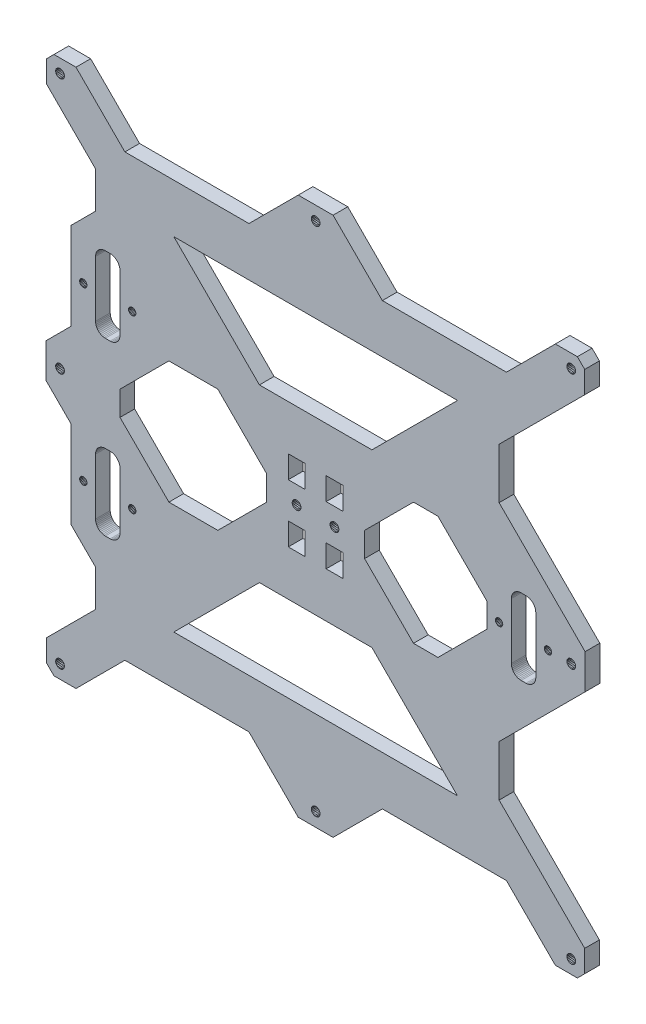
from build123d import *

# Parameters (mm, degrees)
SKETCH1_W           = 6.800001917
SKETCH1_H           = 9.1999977
SKETCH1_H_2         = 9.199995837
BOSS_EXTRUDE1_DEPTH = 6


with BuildPart() as part:
    # Sketch1 → Boss-Extrude1 (new body)
    with BuildSketch(Plane.XY):
        Polygon((253.104853661, 139.09486987), (273.104846061, 159.09486227), (323.830955709, 159.09486227), (343.983501837, 138.942316142), (358.226140366, 138.942316142), (378.378686494, 159.09486227), (429.104796141, 159.09486227), (449.104788541, 139.09486987), (458.104786861, 139.09486987), (461.104785901, 142.09486891), (461.104785901, 151.09486723), (426.104798301, 186.09485483), (426.104798301, 206.820974078), (461.272022357, 241.988198133), (461.272022357, 256.230836662), (426.104798301, 291.398060718), (426.104798301, 312.09481451), (461.104785901, 347.09480211), (461.104785901, 356.09480043), (458.104786861, 359.09479947), (449.104788541, 359.09479947), (429.104796141, 339.09480707), (378.378686494, 339.09480707), (358.226140366, 359.247353198), (343.983501837, 359.247353198), (323.830955709, 339.09480707), (273.104846061, 339.09480707), (253.104853661, 359.09479947), (244.104855341, 359.09479947), (241.104856301, 356.09480043), (241.104856301, 347.09480211), (261.104849901, 327.09480851), (261.104849901, 312.09481451), (251.104853101, 302.09481771), (251.104853101, 266.368704463), (240.937619846, 256.201471208), (240.937619846, 241.958832678), (251.104853101, 231.791599423), (251.104853101, 196.09485163), (261.104849901, 186.09485483), (261.104849901, 171.09486083), (241.104856301, 151.09486723), (241.104856301, 142.09486891), (244.104855341, 139.09486987), align=None)
        Polygon((263.574115382, 229.790358978), (263.104849261, 229.558942537), (262.669803685, 229.268254376), (262.276422402, 228.92326825), (261.931436276, 228.529886967), (261.640748115, 228.09484139), (261.409331674, 227.62557527), (261.241146553, 227.130117879), (261.139070445, 226.616946632), (261.104849901, 226.09484203), (261.104849901, 203.09484939), (261.139070445, 202.572744789), (261.241146553, 202.059573541), (261.409331674, 201.564116151), (261.640748115, 201.09485003), (261.931436276, 200.659804454), (262.276422402, 200.266423171), (262.669803685, 199.921437045), (263.104849261, 199.630748884), (263.574115382, 199.399332443), (264.069572772, 199.231147322), (264.58274402, 199.129071214), (265.104848621, 199.09485067), (267.104847981, 199.09485067), (267.626952583, 199.129071214), (268.140123831, 199.231147322), (268.635581221, 199.399332443), (269.104847341, 199.630748884), (269.539892918, 199.921437045), (269.933274201, 200.266423171), (270.278260327, 200.659804454), (270.568948488, 201.09485003), (270.800364929, 201.564116151), (270.96855005, 202.059573541), (271.070626158, 202.572744789), (271.104846701, 203.09484939), (271.104846701, 226.09484203), (271.070626158, 226.616946632), (270.96855005, 227.130117879), (270.800364929, 227.62557527), (270.568948488, 228.09484139), (270.278260327, 228.529886967), (269.933274201, 228.92326825), (269.539892918, 229.268254376), (269.104847341, 229.558942537), (268.635581221, 229.790358978), (268.140123831, 229.958544099), (267.626952583, 230.060620207), (267.104847981, 230.09484075), (265.104848621, 230.09484075), (264.58274402, 230.060620207), (264.069572772, 229.958544099), align=None, mode=Mode.SUBTRACT)
        Polygon((274.805807411, 284.84482323), (274.655956826, 284.483051914), (274.604845581, 284.09482347), (274.655956826, 283.706595027), (274.805807411, 283.34482371), (275.044185269, 283.034163638), (275.354845341, 282.79578578), (275.716616658, 282.645935195), (276.104845101, 282.59482395), (276.493073545, 282.645935195), (276.854844861, 282.79578578), (277.165504934, 283.034163638), (277.403882791, 283.34482371), (277.553733377, 283.706595027), (277.604844621, 284.09482347), (277.553733377, 284.483051914), (277.403882791, 284.84482323), (277.165504934, 285.155483303), (276.854844861, 285.39386116), (276.493073545, 285.543711746), (276.104845101, 285.59482299), (275.716616658, 285.543711746), (275.354845341, 285.39386116), (275.044185269, 285.155483303), align=None, mode=Mode.SUBTRACT)
        Polygon((445.044130869, 248.034174838), (445.354790941, 247.79579698), (445.716562258, 247.645946395), (446.104790701, 247.59483515), (446.493019145, 247.645946395), (446.854790461, 247.79579698), (447.165450534, 248.034174838), (447.403828391, 248.34483491), (447.553678977, 248.706606227), (447.604790221, 249.09483467), (447.553678977, 249.483063114), (447.403828391, 249.84483443), (447.165450534, 250.155494503), (446.854790461, 250.39387236), (446.493019145, 250.543722946), (446.104790701, 250.59483419), (445.716562258, 250.543722946), (445.354790941, 250.39387236), (445.044130869, 250.155494503), (444.805753011, 249.84483443), (444.655902426, 249.483063114), (444.604791181, 249.09483467), (444.655902426, 248.706606227), (444.805753011, 248.34483491), align=None, mode=Mode.SUBTRACT)
        Polygon((427.403834791, 249.84483443), (427.165456934, 250.155494503), (426.854796861, 250.39387236), (426.493025545, 250.543722946), (426.104797101, 250.59483419), (425.716568658, 250.543722946), (425.354797341, 250.39387236), (425.044137269, 250.155494503), (424.805759411, 249.84483443), (424.655908826, 249.483063114), (424.604797581, 249.09483467), (424.655908826, 248.706606227), (424.805759411, 248.34483491), (425.044137269, 248.034174838), (425.354797341, 247.79579698), (425.716568658, 247.645946395), (426.104797101, 247.59483515), (426.493025545, 247.645946395), (426.854796861, 247.79579698), (427.165456934, 248.034174838), (427.403834791, 248.34483491), (427.553685377, 248.706606227), (427.604796621, 249.09483467), (427.553685377, 249.483063114), align=None, mode=Mode.SUBTRACT)
        Polygon((433.574060982, 263.653224535), (433.104794861, 263.421808094), (432.669749285, 263.131119933), (432.276368002, 262.786133807), (431.931381876, 262.392752524), (431.640693715, 261.957706947), (431.409277274, 261.488440827), (431.241092153, 260.992983436), (431.139016045, 260.479812189), (431.104795501, 259.957707587), (431.104795501, 236.957714947), (431.139016045, 236.435610345), (431.241092153, 235.922439098), (431.409277274, 235.426981708), (431.640693715, 234.957715587), (431.931381876, 234.52267001), (432.276368002, 234.129288728), (432.669749285, 233.784302601), (433.104794861, 233.493614441), (433.574060982, 233.262198), (434.069518372, 233.094012878), (434.58268962, 232.991936771), (435.104794221, 232.957716227), (437.104793581, 232.957716227), (437.626898183, 232.991936771), (438.140069431, 233.094012878), (438.635526821, 233.262198), (439.104792941, 233.493614441), (439.539838518, 233.784302601), (439.933219801, 234.129288728), (440.278205927, 234.52267001), (440.568894088, 234.957715587), (440.800310529, 235.426981708), (440.96849565, 235.922439098), (441.070571758, 236.435610345), (441.104792301, 236.957714947), (441.104792301, 259.957707587), (441.070571758, 260.479812189), (440.96849565, 260.992983436), (440.800310529, 261.488440827), (440.568894088, 261.957706947), (440.278205927, 262.392752524), (439.933219801, 262.786133807), (439.539838518, 263.131119933), (439.104792941, 263.421808094), (438.635526821, 263.653224535), (438.140069431, 263.821409656), (437.626898183, 263.923485764), (437.104793581, 263.957706307), (435.104794221, 263.957706307), (434.58268962, 263.923485764), (434.069518372, 263.821409656), align=None, mode=Mode.SUBTRACT)
        Polygon((270.96855005, 297.137132373), (270.800364929, 297.632589764), (270.568948488, 298.101855884), (270.278260327, 298.536901461), (269.933274201, 298.930282744), (269.539892918, 299.27526887), (269.104847341, 299.565957031), (268.635581221, 299.797373472), (268.140123831, 299.965558593), (267.626952583, 300.067634701), (267.104847981, 300.101855244), (265.104848621, 300.101855244), (264.58274402, 300.067634701), (264.069572772, 299.965558593), (263.574115382, 299.797373472), (263.104849261, 299.565957031), (262.669803685, 299.27526887), (262.276422402, 298.930282744), (261.931436276, 298.536901461), (261.640748115, 298.101855884), (261.409331674, 297.632589764), (261.241146553, 297.137132373), (261.139070445, 296.623961126), (261.104849901, 296.101856524), (261.104849901, 273.101863884), (261.139070445, 272.579759282), (261.241146553, 272.066588035), (261.409331674, 271.571130645), (261.640748115, 271.101864524), (261.931436276, 270.666818947), (262.276422402, 270.273437665), (262.669803685, 269.928451538), (263.104849261, 269.637763378), (263.574115382, 269.406346937), (264.069572772, 269.238161815), (264.58274402, 269.136085708), (265.104848621, 269.101865164), (267.104847981, 269.101865164), (267.626952583, 269.136085708), (268.140123831, 269.238161815), (268.635581221, 269.406346937), (269.104847341, 269.637763378), (269.539892918, 269.928451538), (269.933274201, 270.273437665), (270.278260327, 270.666818947), (270.568948488, 271.101864524), (270.800364929, 271.571130645), (270.96855005, 272.066588035), (271.070626158, 272.579759282), (271.104846701, 273.101863884), (271.104846701, 296.101856524), (271.070626158, 296.623961126), align=None, mode=Mode.SUBTRACT)
        Polygon((276.854844861, 212.79580818), (277.165504934, 213.034186038), (277.403882791, 213.34484611), (277.553733377, 213.706617427), (277.604844621, 214.09484587), (277.553733377, 214.483074314), (277.403882791, 214.84484563), (277.165504934, 215.155505703), (276.854844861, 215.39388356), (276.493073545, 215.543734146), (276.104845101, 215.59484539), (275.716616658, 215.543734146), (275.354845341, 215.39388356), (275.044185269, 215.155505703), (274.805807411, 214.84484563), (274.655956826, 214.483074314), (274.604845581, 214.09484587), (274.655956826, 213.706617427), (274.805807411, 213.34484611), (275.044185269, 213.034186038), (275.354845341, 212.79580818), (275.716616658, 212.645957595), (276.104845101, 212.59484635), (276.493073545, 212.645957595), align=None, mode=Mode.SUBTRACT)
        Polygon((352.663666329, 352.705183774), (352.843487032, 353.139309354), (352.904820525, 353.605183486), (352.843487032, 354.071057619), (352.663666329, 354.505183198), (352.3776129, 354.877975285), (352.038451747, 355.131743055), (352.004820813, 355.164028714), (351.570695234, 355.343849417), (351.104821101, 355.40518291), (350.638946969, 355.343849417), (350.204821389, 355.164028714), (349.832029303, 354.877975285), (349.545975873, 354.505183198), (349.36615517, 354.071057619), (349.304821677, 353.605183486), (349.36615517, 353.139309354), (349.545975873, 352.705183774), (349.832029303, 352.332391688), (350.204821389, 352.046338258), (350.638946969, 351.866517555), (351.104821101, 351.805184062), (351.570695234, 351.866517555), (352.004820813, 352.046338258), (352.3776129, 352.332391688), align=None, mode=Mode.SUBTRACT)
        Polygon((256.104851501, 285.59482299), (255.716623058, 285.543711746), (255.354851741, 285.39386116), (255.044191669, 285.155483303), (254.805813811, 284.84482323), (254.655963226, 284.483051914), (254.604851981, 284.09482347), (254.655963226, 283.706595027), (254.805813811, 283.34482371), (255.044191669, 283.034163638), (255.354851741, 282.79578578), (255.716623058, 282.645935195), (256.104851501, 282.59482395), (256.493079945, 282.645935195), (256.854851261, 282.79578578), (257.165511334, 283.034163638), (257.403889191, 283.34482371), (257.553739777, 283.706595027), (257.604851021, 284.09482347), (257.553739777, 284.483051914), (257.403889191, 284.84482323), (257.165511334, 285.155483303), (256.854851261, 285.39386116), (256.493079945, 285.543711746), align=None, mode=Mode.SUBTRACT)
        Polygon((350.204821389, 146.143331082), (349.832029303, 145.857277653), (349.545975873, 145.484485566), (349.36615517, 145.050359986), (349.304821677, 144.584485854), (349.36615517, 144.118611722), (349.545975873, 143.684486142), (349.832029303, 143.311694055), (350.171190455, 143.057926285), (350.204821389, 143.025640626), (350.638946969, 142.845819923), (351.104821101, 142.78448643), (351.570695234, 142.845819923), (352.004820813, 143.025640626), (352.3776129, 143.311694055), (352.663666329, 143.684486142), (352.843487032, 144.118611722), (352.904820525, 144.584485854), (352.843487032, 145.050359986), (352.663666329, 145.484485566), (352.3776129, 145.857277653), (352.004820813, 146.143331082), (351.570695234, 146.323151785), (351.104821101, 146.384485278), (350.638946969, 146.323151785), align=None, mode=Mode.SUBTRACT)
        Polygon((293.104842061, 319.09481107), (409.104800141, 319.09481107), (374.104812541, 284.09482347), (328.104829661, 284.09482347), align=None, mode=Mode.SUBTRACT)
        Polygon((456.515169629, 146.143331082), (456.08104405, 146.323151785), (455.615169917, 146.384485278), (455.149295785, 146.323151785), (454.715170205, 146.143331082), (454.342378119, 145.857277653), (454.05632469, 145.484485566), (453.876503987, 145.050359986), (453.815170493, 144.584485854), (453.876503987, 144.118611722), (454.05632469, 143.684486142), (454.342378119, 143.311694055), (454.715170205, 143.025640626), (455.149295785, 142.845819923), (455.615169917, 142.78448643), (456.08104405, 142.845819923), (456.515169629, 143.025640626), (456.887961716, 143.311694055), (457.174015145, 143.684486142), (457.353835848, 144.118611722), (457.415169341, 144.584485854), (457.353835848, 145.050359986), (457.174015145, 145.484485566), (456.887961716, 145.857277653), align=None, mode=Mode.SUBTRACT)
        Polygon((245.677096869, 143.056566967), (246.109184437, 142.871902845), (246.57434357, 142.805363492), (247.040874441, 142.861483455), (247.476983743, 143.036438251), (247.852951348, 143.318305001), (248.143155685, 143.68787495), (248.327819807, 144.119962518), (248.39435916, 144.585121651), (248.338239197, 145.051652522), (248.163284401, 145.487761824), (247.881417651, 145.863729429), (247.511847702, 146.153933766), (247.079760134, 146.338597888), (246.614601001, 146.405137241), (246.14807013, 146.349017278), (245.711960827, 146.174062482), (245.335993222, 145.892195732), (245.045788886, 145.522625783), (244.861124764, 145.090538215), (244.794585411, 144.625379082), (244.850705374, 144.158848211), (245.02566017, 143.722738908), (245.30752692, 143.346771303), align=None, mode=Mode.SUBTRACT)
        Polygon((454.356690855, 250.381780036), (454.066486518, 250.012210087), (453.881822396, 249.580122519), (453.815283043, 249.114963386), (453.871403006, 248.648432515), (454.046357802, 248.212323212), (454.328224552, 247.836355607), (454.697794501, 247.546151271), (455.129882069, 247.361487149), (455.595041202, 247.294947796), (456.061572073, 247.351067759), (456.497681376, 247.526022555), (456.87364898, 247.807889305), (457.163853317, 248.177459254), (457.348517439, 248.609546822), (457.415056792, 249.074705955), (457.358936829, 249.541236826), (457.183982033, 249.977346128), (456.902115283, 250.353313733), (456.532545334, 250.64351807), (456.100457766, 250.828182192), (455.635298633, 250.894721545), (455.168767762, 250.838601582), (454.732658459, 250.663646786), align=None, mode=Mode.SUBTRACT)
        Polygon((244.794585411, 249.114963386), (244.850705374, 248.648432515), (245.02566017, 248.212323212), (245.30752692, 247.836355607), (245.677096869, 247.546151271), (246.109184437, 247.361487149), (246.57434357, 247.294947796), (247.040874441, 247.351067759), (247.476983743, 247.526022555), (247.852951348, 247.807889305), (248.143155685, 248.177459254), (248.327819807, 248.609546822), (248.39435916, 249.074705955), (248.338239197, 249.541236826), (248.163284401, 249.977346128), (247.881417651, 250.353313733), (247.511847702, 250.64351807), (247.079760134, 250.828182192), (246.614601001, 250.894721545), (246.14807013, 250.838601582), (245.711960827, 250.663646786), (245.335993222, 250.381780036), (245.045788886, 250.012210087), (244.861124764, 249.580122519), align=None, mode=Mode.SUBTRACT)
        Polygon((331.104827501, 254.09483307), (331.104827501, 244.09483627), (311.104833901, 224.09484267), (291.104840301, 224.09484267), (271.104846701, 244.09483627), (271.104846701, 254.09483307), (291.104840301, 274.09482667), (311.104833901, 274.09482667), align=None, mode=Mode.SUBTRACT)
        Polygon((257.403889191, 214.84484563), (257.165511334, 215.155505703), (256.854851261, 215.39388356), (256.493079945, 215.543734146), (256.104851501, 215.59484539), (255.716623058, 215.543734146), (255.354851741, 215.39388356), (255.044191669, 215.155505703), (254.805813811, 214.84484563), (254.655963226, 214.483074314), (254.604851981, 214.09484587), (254.655963226, 213.706617427), (254.805813811, 213.34484611), (255.044191669, 213.034186038), (255.354851741, 212.79580818), (255.716623058, 212.645957595), (256.104851501, 212.59484635), (256.493079945, 212.645957595), (256.854851261, 212.79580818), (257.165511334, 213.034186038), (257.403889191, 213.34484611), (257.553739777, 213.706617427), (257.604851021, 214.09484587), (257.553739777, 214.483074314), align=None, mode=Mode.SUBTRACT)
        Polygon((245.321680487, 352.332391688), (245.694472573, 352.046338258), (246.128598153, 351.866517555), (246.594472285, 351.805184062), (247.060346417, 351.866517555), (247.494471997, 352.046338258), (247.867264084, 352.332391688), (248.153317513, 352.705183774), (248.333138216, 353.139309354), (248.394471709, 353.605183486), (248.333138216, 354.071057619), (248.153317513, 354.505183198), (247.867264084, 354.877975285), (247.494471997, 355.164028714), (247.060346417, 355.343849417), (246.594472285, 355.40518291), (246.175208223, 355.34480067), (246.128598153, 355.343849417), (245.694472573, 355.164028714), (245.321680487, 354.877975285), (245.035627057, 354.505183198), (244.855806354, 354.071057619), (244.794472861, 353.605183486), (244.855806354, 353.139309354), (245.035627057, 352.705183774), align=None, mode=Mode.SUBTRACT)
        Polygon((421.104798701, 254.09483307), (421.104798701, 244.09483627), (401.104805101, 224.09484267), (391.104808301, 224.09484267), (371.104814701, 244.09483627), (371.104814701, 254.09483307), (391.104808301, 274.09482667), (401.104805101, 274.09482667), align=None, mode=Mode.SUBTRACT)
        Polygon((453.876503987, 354.071057619), (453.815170493, 353.605183486), (453.876503987, 353.139309354), (454.05632469, 352.705183774), (454.342378119, 352.332391688), (454.715170205, 352.046338258), (455.149295785, 351.866517555), (455.615169917, 351.805184062), (456.08104405, 351.866517555), (456.515169629, 352.046338258), (456.887961716, 352.332391688), (457.174015145, 352.705183774), (457.353835848, 353.139309354), (457.415169341, 353.605183486), (457.353835848, 354.071057619), (457.174015145, 354.505183198), (456.887961716, 354.877975285), (456.515169629, 355.164028714), (456.08104405, 355.343849417), (455.615169917, 355.40518291), (455.149295785, 355.343849417), (454.715170205, 355.164028714), (454.342378119, 354.877975285), (454.05632469, 354.505183198), align=None, mode=Mode.SUBTRACT)
        Polygon((328.104829661, 214.09484587), (293.104842061, 179.09485827), (409.104800141, 179.09485827), (374.104812541, 214.09484587), align=None, mode=Mode.SUBTRACT)
        Polygon((342.401463987, 247.569704449), (342.835615299, 247.38994588), (343.301498204, 247.328679064), (343.767363553, 247.390079233), (344.201463393, 247.569962067), (344.574214535, 247.856068848), (344.860214607, 248.228901871), (345.039973176, 248.663053183), (345.101239992, 249.128936088), (345.039839823, 249.594801437), (344.859956989, 250.028901277), (344.573850208, 250.401652419), (344.201017185, 250.687652491), (343.766865873, 250.86741106), (343.300982968, 250.928677875), (342.835117619, 250.867277707), (342.401017779, 250.687394873), (342.028266637, 250.401288092), (341.742266565, 250.028455069), (341.562507996, 249.594303757), (341.50124118, 249.128420852), (341.562641349, 248.662555502), (341.742524183, 248.228455663), (342.028630964, 247.855704521), align=None, mode=Mode.SUBTRACT)
        with Locations((343.302965436, 237.228426072)):
            Rectangle(SKETCH1_W, SKETCH1_H, mode=Mode.SUBTRACT)
        with Locations((343.302965436, 261.028416902)):
            Rectangle(SKETCH1_W, SKETCH1_H_2, mode=Mode.SUBTRACT)
        Polygon((358.799025553, 247.313607898), (359.264890902, 247.375008067), (359.698990741, 247.554890901), (360.071741884, 247.840997681), (360.357741956, 248.213830705), (360.537500524, 248.647982016), (360.59876734, 249.113864922), (360.537367171, 249.579730271), (360.357484338, 250.01383011), (360.071377557, 250.386581253), (359.698544534, 250.672581325), (359.264393222, 250.852339893), (358.798510316, 250.913606709), (358.332644967, 250.85220654), (357.898545128, 250.672323706), (357.525793985, 250.386216926), (357.239793914, 250.013383902), (357.060035345, 249.579232591), (356.998768529, 249.113349685), (357.060168698, 248.647484336), (357.240051532, 248.213384497), (357.526158312, 247.840633354), (357.898991336, 247.554633282), (358.333142647, 247.374874714), align=None, mode=Mode.SUBTRACT)
        with Locations((358.800492784, 237.213354906)):
            Rectangle(SKETCH1_W, SKETCH1_H, mode=Mode.SUBTRACT)
        with Locations((358.800492784, 261.013345736)):
            Rectangle(SKETCH1_W, SKETCH1_H_2, mode=Mode.SUBTRACT)
    extrude(amount=BOSS_EXTRUDE1_DEPTH)


solid = part.part
